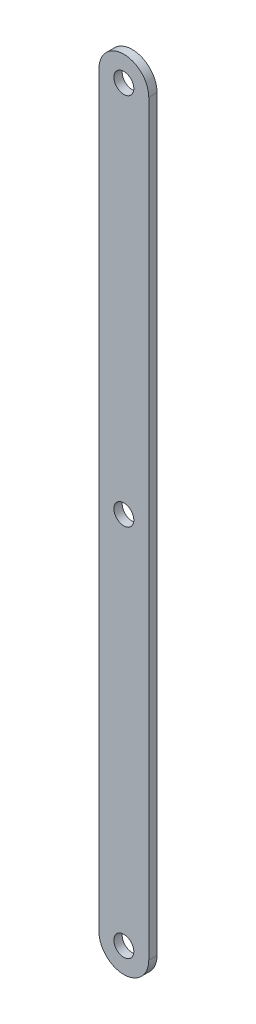
from build123d import *

# Parameters (mm, degrees)
SKETCH_1_R      = 6
EXTRUDE_1_DEPTH = 5


with BuildPart() as part:
    # 草图1 → 凸台-拉伸1 (new body)
    with BuildSketch(Plane.XY):
        with BuildLine():
            Line((8.363113875, 62.695768031), (8.363113875, 512.695768031))
            ThreePointArc((8.363113875, 512.695768031), (23.363113875, 527.695768031), (38.363113875, 512.695768031))
            Line((38.363113875, 512.695768031), (38.363113875, 62.695768031))
            ThreePointArc((38.363113875, 62.695768031), (23.363113875, 47.695768031), (8.363113875, 62.695768031))
        make_face()
        with Locations((23.363113875, 512.695768031)):
            Circle(SKETCH_1_R, mode=Mode.SUBTRACT)
        with Locations((23.363113875, 62.695768031)):
            Circle(SKETCH_1_R, mode=Mode.SUBTRACT)
        with Locations((23.363113875, 287.695768031)):
            Circle(SKETCH_1_R, mode=Mode.SUBTRACT)
    extrude(amount=EXTRUDE_1_DEPTH)


solid = part.part
